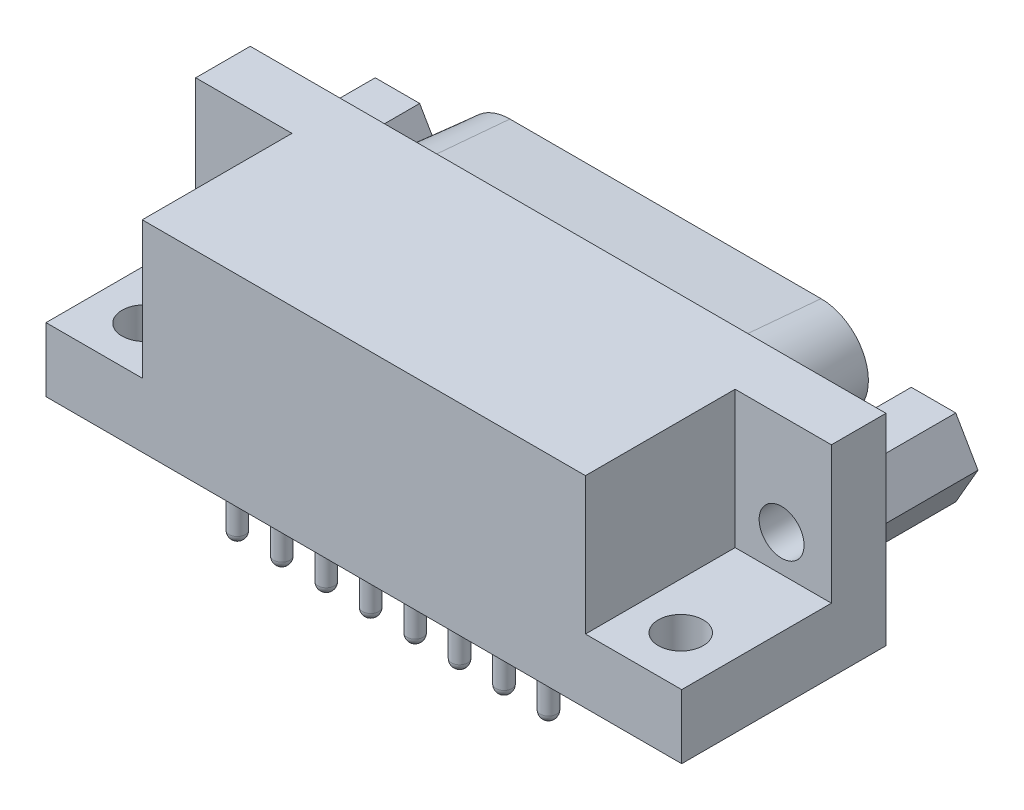
from build123d import *

# Parameters (mm, degrees)
SKETCH1_W                    = 39.62
SKETCH1_H                    = 12.55
BASE_EXTRUDE_DEPTH           = 1.77
BASE_EXTRUDE_DEPTH_BACK      = 10.96
SKETCH2_W                    = 7
SKETCH2_H                    = 10
CUT_EXTRUDE1_DEPTH           = 8.55
SKETCH4_R                    = 1.4
CUT_EXTRUDE3_DEPTH           = 33.652568291
SKETCH5_R                    = 1.4
CUT_EXTRUDE4_DEPTH           = 3
BOSS_EXTRUDE1_DEPTH          = 6.07
SKETCH7_R                    = 1.4
CUT_EXTRUDE5_DEPTH           = 6.07
BOSS_EXTRUDE3_DEPTH          = 6.07
BOSS_EXTRUDE3_TAPER          = 5
CUT_EXTRUDE7_DEPTH           = 6.07
CUT_EXTRUDE7_DRAFT           = 5
BOSS_EXTRUDE4_DEPTH          = 0.6
CUT_EXTRUDE8_START           = -0.6
SKETCH14_R                   = 0.75
CUT_EXTRUDE8_DEPTH           = 0.6
LPATTERN1_COUNT              = 7
LPATTERN1_PITCH              = 2.77
CUT_EXTRUDE9_START           = -0.6
SKETCH15_R                   = 0.75
CUT_EXTRUDE9_DEPTH           = 0.6
LPATTERN2_COUNT              = 8
LPATTERN2_PITCH              = 2.77
SKETCH16_R                   = 0.5
BOSS_EXTRUDE5_DEPTH          = 4.6
DOME1_FACE_RADIUS            = 0.5
DOME1_HEIGHT                 = 0.5
LPATTERN3_COUNT              = 7
LPATTERN3_PITCH              = 2.77
LPATTERN3_COPY_1_FACE_RADIUS = 0.5
LPATTERN3_COPY_1_HEIGHT      = 0.5
LPATTERN3_COPY_2_FACE_RADIUS = 0.5
LPATTERN3_COPY_2_HEIGHT      = 0.5
LPATTERN3_COPY_3_FACE_RADIUS = 0.5
LPATTERN3_COPY_3_HEIGHT      = 0.5
LPATTERN3_COPY_4_FACE_RADIUS = 0.5
LPATTERN3_COPY_4_HEIGHT      = 0.5
LPATTERN3_COPY_5_FACE_RADIUS = 0.5
LPATTERN3_COPY_5_HEIGHT      = 0.5
LPATTERN3_COPY_6_FACE_RADIUS = 0.5
LPATTERN3_COPY_6_HEIGHT      = 0.5
SKETCH17_R                   = 0.5
BOSS_EXTRUDE6_DEPTH          = 4.6
DOME2_FACE_RADIUS            = 0.5
DOME2_HEIGHT                 = 0.5
LPATTERN5_COUNT              = 8
LPATTERN5_PITCH              = 2.77
LPATTERN5_COPY_1_FACE_RADIUS = 0.5
LPATTERN5_COPY_1_HEIGHT      = 0.5
LPATTERN5_COPY_2_FACE_RADIUS = 0.5
LPATTERN5_COPY_2_HEIGHT      = 0.5
LPATTERN5_COPY_3_FACE_RADIUS = 0.5
LPATTERN5_COPY_3_HEIGHT      = 0.5
LPATTERN5_COPY_4_FACE_RADIUS = 0.5
LPATTERN5_COPY_4_HEIGHT      = 0.5
LPATTERN5_COPY_5_FACE_RADIUS = 0.5
LPATTERN5_COPY_5_HEIGHT      = 0.5
LPATTERN5_COPY_6_FACE_RADIUS = 0.5
LPATTERN5_COPY_6_HEIGHT      = 0.5
LPATTERN5_COPY_7_FACE_RADIUS = 0.5
LPATTERN5_COPY_7_HEIGHT      = 0.5
SKETCH18_R                   = 0.5
BOSS_EXTRUDE7_DEPTH          = 3
DOME3_FACE_RADIUS            = 0.5
DOME3_HEIGHT                 = 0.5
LPATTERN7_COUNT              = 8
LPATTERN7_PITCH              = 2.77
LPATTERN7_COPY_1_FACE_RADIUS = 0.5
LPATTERN7_COPY_1_HEIGHT      = 0.5
LPATTERN7_COPY_2_FACE_RADIUS = 0.5
LPATTERN7_COPY_2_HEIGHT      = 0.5
LPATTERN7_COPY_3_FACE_RADIUS = 0.5
LPATTERN7_COPY_3_HEIGHT      = 0.5
LPATTERN7_COPY_4_FACE_RADIUS = 0.5
LPATTERN7_COPY_4_HEIGHT      = 0.5
LPATTERN7_COPY_5_FACE_RADIUS = 0.5
LPATTERN7_COPY_5_HEIGHT      = 0.5
LPATTERN7_COPY_6_FACE_RADIUS = 0.5
LPATTERN7_COPY_6_HEIGHT      = 0.5
LPATTERN7_COPY_7_FACE_RADIUS = 0.5
LPATTERN7_COPY_7_HEIGHT      = 0.5
SKETCH19_R                   = 0.5
BOSS_EXTRUDE8_DEPTH          = 3
DOME4_FACE_RADIUS            = 0.5
DOME4_HEIGHT                 = 0.5
LPATTERN9_COUNT              = 7
LPATTERN9_PITCH              = 2.77
LPATTERN9_COPY_1_FACE_RADIUS = 0.5
LPATTERN9_COPY_1_HEIGHT      = 0.5
LPATTERN9_COPY_2_FACE_RADIUS = 0.5
LPATTERN9_COPY_2_HEIGHT      = 0.5
LPATTERN9_COPY_3_FACE_RADIUS = 0.5
LPATTERN9_COPY_3_HEIGHT      = 0.5
LPATTERN9_COPY_4_FACE_RADIUS = 0.5
LPATTERN9_COPY_4_HEIGHT      = 0.5
LPATTERN9_COPY_5_FACE_RADIUS = 0.5
LPATTERN9_COPY_5_HEIGHT      = 0.5
LPATTERN9_COPY_6_FACE_RADIUS = 0.5
LPATTERN9_COPY_6_HEIGHT      = 0.5


with BuildPart() as part:
    # Sketch1 → Base-Extrude (new, two sides)
    with BuildSketch(Plane.XY) as base_extrude_sk:
        with Locations((-9.736, 6.275)):
            Rectangle(SKETCH1_W, SKETCH1_H)
    extrude(amount=BASE_EXTRUDE_DEPTH)
    extrude(base_extrude_sk.sketch, amount=-BASE_EXTRUDE_DEPTH_BACK)

    # Sketch2 → Cut-Extrude1 (cut)
    with BuildSketch(Plane(origin=(0, 12.55, 0), x_dir=(-1, 0, 0), z_dir=(0, 1, 0))):
        with Locations((-7.574, -2.56)):
            Rectangle(SKETCH2_W, SKETCH2_H)
    cut_extrude1 = extrude(amount=-CUT_EXTRUDE1_DEPTH, mode=Mode.SUBTRACT)

    # Sketch4 → Cut-Extrude3 (cut, through all)
    with BuildSketch(Plane(origin=(0, 4, 0), x_dir=(-1, 0, 0), z_dir=(0, 1, 0))):
        with Locations(Location((-6.975, -1.27, 0), (0, 0, 90))):
            Circle(SKETCH4_R)
    cut_extrude3 = extrude(amount=-CUT_EXTRUDE3_DEPTH, mode=Mode.SUBTRACT)

    # Sketch5 → Cut-Extrude4 (cut)
    with BuildSketch(Plane.XY.offset(-7.56)):
        with Locations((6.97, 6.275)):
            Circle(SKETCH5_R)
    cut_extrude4 = extrude(amount=-CUT_EXTRUDE4_DEPTH, mode=Mode.SUBTRACT)

    # Sketch6 → Boss-Extrude1 (add)
    with BuildSketch(Plane(origin=(0, 0, -10.96), x_dir=(-1, 0, 0), z_dir=(0, 0, -1))):
        Polygon((-5.584359354, 8.675), (-8.355640646, 8.675), (-9.741281292, 6.275), (-8.355640646, 3.875), (-5.584359354, 3.875), (-4.198718708, 6.275), align=None)
    boss_extrude1 = extrude(amount=BOSS_EXTRUDE1_DEPTH)

    # Sketch7 → Cut-Extrude5 (cut)
    with BuildSketch(Plane(origin=(0, 0, -17.03), x_dir=(-1, 0, 0), z_dir=(0, 0, -1))):
        with Locations(Location((-6.97, 6.275, 0), (0, 0, 180))):
            Circle(SKETCH7_R)
    cut_extrude5 = extrude(amount=-CUT_EXTRUDE5_DEPTH, mode=Mode.SUBTRACT)

    # Mirror1: Cut-Extrude1, Cut-Extrude3, Cut-Extrude4, Boss-Extrude1, Cut-Extrude5 across plane
    add(cut_extrude1.mirror(Plane(origin=(-9.736, 0, 0), x_dir=(0, 0, 1), z_dir=(1, 0, 0))), mode=Mode.SUBTRACT)
    add(cut_extrude3.mirror(Plane(origin=(-9.736, 0, 0), x_dir=(0, 0, 1), z_dir=(1, 0, 0))), mode=Mode.SUBTRACT)
    add(cut_extrude4.mirror(Plane(origin=(-9.736, 0, 0), x_dir=(0, 0, 1), z_dir=(1, 0, 0))), mode=Mode.SUBTRACT)
    add(boss_extrude1.mirror(Plane(origin=(-9.736, 0, 0), x_dir=(0, 0, 1), z_dir=(1, 0, 0))))
    add(cut_extrude5.mirror(Plane(origin=(-9.736, 0, 0), x_dir=(0, 0, 1), z_dir=(1, 0, 0))), mode=Mode.SUBTRACT)

    # Sketch8 → Boss-Extrude3 (add)
    with BuildSketch(Plane(origin=(0, 0, -10.96), x_dir=(-1, 0, 0), z_dir=(0, 0, -1))):
        with BuildLine():
            ThreePointArc((18.046, 1.3739), (19.890769362, 1.902901897), (21.174861644, 3.329129093))
            Line((21.174861644, 3.329129093), (22.559861644, 6.169129093))
            ThreePointArc((22.559861644, 6.169129093), (22.383098103, 9.539769362), (19.431, 11.1761))
            Line((19.431, 11.1761), (0.041, 11.1761))
            ThreePointArc((0.041, 11.1761), (-2.911098103, 9.539769362), (-3.087861644, 6.169129093))
            Line((-3.087861644, 6.169129093), (-1.702861644, 3.329129093))
            ThreePointArc((-1.702861644, 3.329129093), (-0.418769362, 1.902901897), (1.426, 1.3739))
            Line((1.426, 1.3739), (18.046, 1.3739))
        make_face()
    extrude(amount=BOSS_EXTRUDE3_DEPTH, taper=BOSS_EXTRUDE3_TAPER)


with BuildPart() as cut_extrude7_tool:
    # Sketch12 → Cut-Extrude7 (with draft: the straight prism first)
    with BuildSketch(Plane(origin=(0, 0, -17.03), x_dir=(-1, 0, 0), z_dir=(0, 0, -1))):
        with BuildLine():
            Line((-2.251015246, 6.577239044), (-0.866015246, 3.737239044))
            ThreePointArc((-0.866015246, 3.737239044), (0.074633278, 2.692471057), (1.426, 2.304956188))
            Line((1.426, 2.304956188), (18.046, 2.304956188))
            ThreePointArc((18.046, 2.304956188), (19.397366722, 2.692471057), (20.338015246, 3.737239044))
            Line((20.338015246, 3.737239044), (21.723015246, 6.577239044))
            ThreePointArc((21.723015246, 6.577239044), (21.593528943, 9.046366722), (19.431, 10.245043812))
            Line((19.431, 10.245043812), (0.041, 10.245043812))
            ThreePointArc((0.041, 10.245043812), (-2.121528943, 9.046366722), (-2.251015246, 6.577239044))
        make_face()
    extrude(amount=-CUT_EXTRUDE7_DEPTH)
    # Cut-Extrude7: the draft: its side faces are tilted about the plane it starts from
    cut_extrude7_sides = [cut_extrude7_tool.faces().sort_by_distance(p)[0] for p in [
        (1.558515246, 5.157239044, -13.995),
        (-0.074633278, 2.692471057, -13.995),
        (-9.736, 2.304956188, -13.995),
        (-19.397366722, 2.692471057, -13.995),
        (-21.030515246, 5.157239044, -13.995),
        (-21.593528943, 9.046366722, -13.995),
        (-9.736, 10.245043812, -13.995),
        (2.121528943, 9.046366722, -13.995),
    ]]
    draft(cut_extrude7_sides, Plane(origin=(0, 0, -17.03), x_dir=(-1, 0, 0), z_dir=(0, 0, -1)), CUT_EXTRUDE7_DRAFT)


with BuildPart() as part_1:
    add(part.part)

    # Cut-Extrude7: cut by cut_extrude7_tool
    add(cut_extrude7_tool.part, mode=Mode.SUBTRACT)

    # Sketch13 → Boss-Extrude4 (add)
    with BuildSketch(Plane(origin=(0, 0, -10.96), x_dir=(-1, 0, 0), z_dir=(0, 0, -1))):
        with BuildLine():
            Line((-2.241987726, 6.581641549), (-0.856987726, 3.741641549))
            ThreePointArc((-0.856987726, 3.741641549), (0.079955882, 2.700988572), (1.426, 2.315))
            Line((1.426, 2.315), (18.046, 2.315))
            ThreePointArc((18.046, 2.315), (19.392044118, 2.700988572), (20.328987726, 3.741641549))
            Line((20.328987726, 3.741641549), (21.713987726, 6.581641549))
            ThreePointArc((21.713987726, 6.581641549), (21.585011428, 9.041044118), (19.431, 10.235))
            Line((19.431, 10.235), (0.041, 10.235))
            ThreePointArc((0.041, 10.235), (-2.113011428, 9.041044118), (-2.241987726, 6.581641549))
        make_face()
    extrude(amount=BOSS_EXTRUDE4_DEPTH)

    # Sketch14 → Cut-Extrude8 (cut)
    with BuildSketch(Plane(origin=(0, 0, -11.56), x_dir=(-1, 0, 0), z_dir=(0, 0, -1)).offset(CUT_EXTRUDE8_START)):
        with Locations((1.426, 4.855)):
            Circle(SKETCH14_R)
    cut_extrude8 = extrude(amount=CUT_EXTRUDE8_DEPTH, mode=Mode.SUBTRACT)

    # LPattern1: Cut-Extrude8 ×7
    with Locations(*[(-i * LPATTERN1_PITCH, 0, 0) for i in range(1, LPATTERN1_COUNT)]):
        add(cut_extrude8, mode=Mode.SUBTRACT)

    # Sketch15 → Cut-Extrude9 (cut)
    with BuildSketch(Plane(origin=(0, 0, -11.56), x_dir=(-1, 0, 0), z_dir=(0, 0, -1)).offset(CUT_EXTRUDE9_START)):
        with Locations((0.041, 7.695)):
            Circle(SKETCH15_R)
    cut_extrude9 = extrude(amount=CUT_EXTRUDE9_DEPTH, mode=Mode.SUBTRACT)

    # LPattern2: Cut-Extrude9 ×8
    with Locations(*[(-i * LPATTERN2_PITCH, 0, 0) for i in range(1, LPATTERN2_COUNT)]):
        add(cut_extrude9, mode=Mode.SUBTRACT)

    # Sketch16 → Boss-Extrude5 (add)
    with BuildSketch(Plane(origin=(0, 0, -10.96), x_dir=(-1, 0, 0), z_dir=(0, 0, -1))):
        with Locations(Location((1.426, 4.855, 0), (0, 0, 180))):
            Circle(SKETCH16_R)
    boss_extrude5 = extrude(amount=BOSS_EXTRUDE5_DEPTH)

    # Dome1: a dome of height H over a round flat face of radius A is a cap of a sphere of radius (A * A + H * H) / (2 * H)
    dome1_r = (DOME1_FACE_RADIUS * DOME1_FACE_RADIUS + DOME1_HEIGHT * DOME1_HEIGHT) / (2 * DOME1_HEIGHT)
    dome1_base = Plane((-1.426, 4.855, -15.56), z_dir=(0, 0, -1))
    with Locations(dome1_base.offset(DOME1_HEIGHT - dome1_r)):
        dome1_ball = Sphere(dome1_r, mode=Mode.PRIVATE)
    add(split(dome1_ball, bisect_by=dome1_base, keep=Keep.TOP, mode=Mode.PRIVATE))

    # LPattern3: Boss-Extrude5 ×7
    with Locations(*[(-i * LPATTERN3_PITCH, 0, 0) for i in range(1, LPATTERN3_COUNT)]):
        add(boss_extrude5)

    # LPattern3 copy 1: a dome of height H over a round flat face of radius A is a cap of a sphere of radius (A * A + H * H) / (2 * H)
    lpattern3_copy_1_r = (LPATTERN3_COPY_1_FACE_RADIUS * LPATTERN3_COPY_1_FACE_RADIUS + LPATTERN3_COPY_1_HEIGHT * LPATTERN3_COPY_1_HEIGHT) / (2 * LPATTERN3_COPY_1_HEIGHT)
    lpattern3_copy_1_base = Plane((-4.196, 4.855, -15.56), z_dir=(0, 0, -1))
    with Locations(lpattern3_copy_1_base.offset(LPATTERN3_COPY_1_HEIGHT - lpattern3_copy_1_r)):
        lpattern3_copy_1_ball = Sphere(lpattern3_copy_1_r, mode=Mode.PRIVATE)
    add(split(lpattern3_copy_1_ball, bisect_by=lpattern3_copy_1_base, keep=Keep.TOP, mode=Mode.PRIVATE))

    # LPattern3 copy 2: a dome of height H over a round flat face of radius A is a cap of a sphere of radius (A * A + H * H) / (2 * H)
    lpattern3_copy_2_r = (LPATTERN3_COPY_2_FACE_RADIUS * LPATTERN3_COPY_2_FACE_RADIUS + LPATTERN3_COPY_2_HEIGHT * LPATTERN3_COPY_2_HEIGHT) / (2 * LPATTERN3_COPY_2_HEIGHT)
    lpattern3_copy_2_base = Plane((-6.966, 4.855, -15.56), z_dir=(0, 0, -1))
    with Locations(lpattern3_copy_2_base.offset(LPATTERN3_COPY_2_HEIGHT - lpattern3_copy_2_r)):
        lpattern3_copy_2_ball = Sphere(lpattern3_copy_2_r, mode=Mode.PRIVATE)
    add(split(lpattern3_copy_2_ball, bisect_by=lpattern3_copy_2_base, keep=Keep.TOP, mode=Mode.PRIVATE))

    # LPattern3 copy 3: a dome of height H over a round flat face of radius A is a cap of a sphere of radius (A * A + H * H) / (2 * H)
    lpattern3_copy_3_r = (LPATTERN3_COPY_3_FACE_RADIUS * LPATTERN3_COPY_3_FACE_RADIUS + LPATTERN3_COPY_3_HEIGHT * LPATTERN3_COPY_3_HEIGHT) / (2 * LPATTERN3_COPY_3_HEIGHT)
    lpattern3_copy_3_base = Plane((-9.736, 4.855, -15.56), z_dir=(0, 0, -1))
    with Locations(lpattern3_copy_3_base.offset(LPATTERN3_COPY_3_HEIGHT - lpattern3_copy_3_r)):
        lpattern3_copy_3_ball = Sphere(lpattern3_copy_3_r, mode=Mode.PRIVATE)
    add(split(lpattern3_copy_3_ball, bisect_by=lpattern3_copy_3_base, keep=Keep.TOP, mode=Mode.PRIVATE))

    # LPattern3 copy 4: a dome of height H over a round flat face of radius A is a cap of a sphere of radius (A * A + H * H) / (2 * H)
    lpattern3_copy_4_r = (LPATTERN3_COPY_4_FACE_RADIUS * LPATTERN3_COPY_4_FACE_RADIUS + LPATTERN3_COPY_4_HEIGHT * LPATTERN3_COPY_4_HEIGHT) / (2 * LPATTERN3_COPY_4_HEIGHT)
    lpattern3_copy_4_base = Plane((-12.506, 4.855, -15.56), z_dir=(0, 0, -1))
    with Locations(lpattern3_copy_4_base.offset(LPATTERN3_COPY_4_HEIGHT - lpattern3_copy_4_r)):
        lpattern3_copy_4_ball = Sphere(lpattern3_copy_4_r, mode=Mode.PRIVATE)
    add(split(lpattern3_copy_4_ball, bisect_by=lpattern3_copy_4_base, keep=Keep.TOP, mode=Mode.PRIVATE))

    # LPattern3 copy 5: a dome of height H over a round flat face of radius A is a cap of a sphere of radius (A * A + H * H) / (2 * H)
    lpattern3_copy_5_r = (LPATTERN3_COPY_5_FACE_RADIUS * LPATTERN3_COPY_5_FACE_RADIUS + LPATTERN3_COPY_5_HEIGHT * LPATTERN3_COPY_5_HEIGHT) / (2 * LPATTERN3_COPY_5_HEIGHT)
    lpattern3_copy_5_base = Plane((-15.276, 4.855, -15.56), z_dir=(0, 0, -1))
    with Locations(lpattern3_copy_5_base.offset(LPATTERN3_COPY_5_HEIGHT - lpattern3_copy_5_r)):
        lpattern3_copy_5_ball = Sphere(lpattern3_copy_5_r, mode=Mode.PRIVATE)
    add(split(lpattern3_copy_5_ball, bisect_by=lpattern3_copy_5_base, keep=Keep.TOP, mode=Mode.PRIVATE))

    # LPattern3 copy 6: a dome of height H over a round flat face of radius A is a cap of a sphere of radius (A * A + H * H) / (2 * H)
    lpattern3_copy_6_r = (LPATTERN3_COPY_6_FACE_RADIUS * LPATTERN3_COPY_6_FACE_RADIUS + LPATTERN3_COPY_6_HEIGHT * LPATTERN3_COPY_6_HEIGHT) / (2 * LPATTERN3_COPY_6_HEIGHT)
    lpattern3_copy_6_base = Plane((-18.046, 4.855, -15.56), z_dir=(0, 0, -1))
    with Locations(lpattern3_copy_6_base.offset(LPATTERN3_COPY_6_HEIGHT - lpattern3_copy_6_r)):
        lpattern3_copy_6_ball = Sphere(lpattern3_copy_6_r, mode=Mode.PRIVATE)
    add(split(lpattern3_copy_6_ball, bisect_by=lpattern3_copy_6_base, keep=Keep.TOP, mode=Mode.PRIVATE))

    # Sketch17 → Boss-Extrude6 (add)
    with BuildSketch(Plane(origin=(0, 0, -10.96), x_dir=(-1, 0, 0), z_dir=(0, 0, -1))):
        with Locations(Location((0.041, 7.695, 0), (0, 0, 180))):
            Circle(SKETCH17_R)
    boss_extrude6 = extrude(amount=BOSS_EXTRUDE6_DEPTH)

    # Dome2: a dome of height H over a round flat face of radius A is a cap of a sphere of radius (A * A + H * H) / (2 * H)
    dome2_r = (DOME2_FACE_RADIUS * DOME2_FACE_RADIUS + DOME2_HEIGHT * DOME2_HEIGHT) / (2 * DOME2_HEIGHT)
    dome2_base = Plane((-0.041, 7.695, -15.56), z_dir=(0, 0, -1))
    with Locations(dome2_base.offset(DOME2_HEIGHT - dome2_r)):
        dome2_ball = Sphere(dome2_r, mode=Mode.PRIVATE)
    add(split(dome2_ball, bisect_by=dome2_base, keep=Keep.TOP, mode=Mode.PRIVATE))

    # LPattern5: Boss-Extrude6 ×8
    with Locations(*[(-i * LPATTERN5_PITCH, 0, 0) for i in range(1, LPATTERN5_COUNT)]):
        add(boss_extrude6)

    # LPattern5 copy 1: a dome of height H over a round flat face of radius A is a cap of a sphere of radius (A * A + H * H) / (2 * H)
    lpattern5_copy_1_r = (LPATTERN5_COPY_1_FACE_RADIUS * LPATTERN5_COPY_1_FACE_RADIUS + LPATTERN5_COPY_1_HEIGHT * LPATTERN5_COPY_1_HEIGHT) / (2 * LPATTERN5_COPY_1_HEIGHT)
    lpattern5_copy_1_base = Plane((-2.811, 7.695, -15.56), z_dir=(0, 0, -1))
    with Locations(lpattern5_copy_1_base.offset(LPATTERN5_COPY_1_HEIGHT - lpattern5_copy_1_r)):
        lpattern5_copy_1_ball = Sphere(lpattern5_copy_1_r, mode=Mode.PRIVATE)
    add(split(lpattern5_copy_1_ball, bisect_by=lpattern5_copy_1_base, keep=Keep.TOP, mode=Mode.PRIVATE))

    # LPattern5 copy 2: a dome of height H over a round flat face of radius A is a cap of a sphere of radius (A * A + H * H) / (2 * H)
    lpattern5_copy_2_r = (LPATTERN5_COPY_2_FACE_RADIUS * LPATTERN5_COPY_2_FACE_RADIUS + LPATTERN5_COPY_2_HEIGHT * LPATTERN5_COPY_2_HEIGHT) / (2 * LPATTERN5_COPY_2_HEIGHT)
    lpattern5_copy_2_base = Plane((-5.581, 7.695, -15.56), z_dir=(0, 0, -1))
    with Locations(lpattern5_copy_2_base.offset(LPATTERN5_COPY_2_HEIGHT - lpattern5_copy_2_r)):
        lpattern5_copy_2_ball = Sphere(lpattern5_copy_2_r, mode=Mode.PRIVATE)
    add(split(lpattern5_copy_2_ball, bisect_by=lpattern5_copy_2_base, keep=Keep.TOP, mode=Mode.PRIVATE))

    # LPattern5 copy 3: a dome of height H over a round flat face of radius A is a cap of a sphere of radius (A * A + H * H) / (2 * H)
    lpattern5_copy_3_r = (LPATTERN5_COPY_3_FACE_RADIUS * LPATTERN5_COPY_3_FACE_RADIUS + LPATTERN5_COPY_3_HEIGHT * LPATTERN5_COPY_3_HEIGHT) / (2 * LPATTERN5_COPY_3_HEIGHT)
    lpattern5_copy_3_base = Plane((-8.351, 7.695, -15.56), z_dir=(0, 0, -1))
    with Locations(lpattern5_copy_3_base.offset(LPATTERN5_COPY_3_HEIGHT - lpattern5_copy_3_r)):
        lpattern5_copy_3_ball = Sphere(lpattern5_copy_3_r, mode=Mode.PRIVATE)
    add(split(lpattern5_copy_3_ball, bisect_by=lpattern5_copy_3_base, keep=Keep.TOP, mode=Mode.PRIVATE))

    # LPattern5 copy 4: a dome of height H over a round flat face of radius A is a cap of a sphere of radius (A * A + H * H) / (2 * H)
    lpattern5_copy_4_r = (LPATTERN5_COPY_4_FACE_RADIUS * LPATTERN5_COPY_4_FACE_RADIUS + LPATTERN5_COPY_4_HEIGHT * LPATTERN5_COPY_4_HEIGHT) / (2 * LPATTERN5_COPY_4_HEIGHT)
    lpattern5_copy_4_base = Plane((-11.121, 7.695, -15.56), z_dir=(0, 0, -1))
    with Locations(lpattern5_copy_4_base.offset(LPATTERN5_COPY_4_HEIGHT - lpattern5_copy_4_r)):
        lpattern5_copy_4_ball = Sphere(lpattern5_copy_4_r, mode=Mode.PRIVATE)
    add(split(lpattern5_copy_4_ball, bisect_by=lpattern5_copy_4_base, keep=Keep.TOP, mode=Mode.PRIVATE))

    # LPattern5 copy 5: a dome of height H over a round flat face of radius A is a cap of a sphere of radius (A * A + H * H) / (2 * H)
    lpattern5_copy_5_r = (LPATTERN5_COPY_5_FACE_RADIUS * LPATTERN5_COPY_5_FACE_RADIUS + LPATTERN5_COPY_5_HEIGHT * LPATTERN5_COPY_5_HEIGHT) / (2 * LPATTERN5_COPY_5_HEIGHT)
    lpattern5_copy_5_base = Plane((-13.891, 7.695, -15.56), z_dir=(0, 0, -1))
    with Locations(lpattern5_copy_5_base.offset(LPATTERN5_COPY_5_HEIGHT - lpattern5_copy_5_r)):
        lpattern5_copy_5_ball = Sphere(lpattern5_copy_5_r, mode=Mode.PRIVATE)
    add(split(lpattern5_copy_5_ball, bisect_by=lpattern5_copy_5_base, keep=Keep.TOP, mode=Mode.PRIVATE))

    # LPattern5 copy 6: a dome of height H over a round flat face of radius A is a cap of a sphere of radius (A * A + H * H) / (2 * H)
    lpattern5_copy_6_r = (LPATTERN5_COPY_6_FACE_RADIUS * LPATTERN5_COPY_6_FACE_RADIUS + LPATTERN5_COPY_6_HEIGHT * LPATTERN5_COPY_6_HEIGHT) / (2 * LPATTERN5_COPY_6_HEIGHT)
    lpattern5_copy_6_base = Plane((-16.661, 7.695, -15.56), z_dir=(0, 0, -1))
    with Locations(lpattern5_copy_6_base.offset(LPATTERN5_COPY_6_HEIGHT - lpattern5_copy_6_r)):
        lpattern5_copy_6_ball = Sphere(lpattern5_copy_6_r, mode=Mode.PRIVATE)
    add(split(lpattern5_copy_6_ball, bisect_by=lpattern5_copy_6_base, keep=Keep.TOP, mode=Mode.PRIVATE))

    # LPattern5 copy 7: a dome of height H over a round flat face of radius A is a cap of a sphere of radius (A * A + H * H) / (2 * H)
    lpattern5_copy_7_r = (LPATTERN5_COPY_7_FACE_RADIUS * LPATTERN5_COPY_7_FACE_RADIUS + LPATTERN5_COPY_7_HEIGHT * LPATTERN5_COPY_7_HEIGHT) / (2 * LPATTERN5_COPY_7_HEIGHT)
    lpattern5_copy_7_base = Plane((-19.431, 7.695, -15.56), z_dir=(0, 0, -1))
    with Locations(lpattern5_copy_7_base.offset(LPATTERN5_COPY_7_HEIGHT - lpattern5_copy_7_r)):
        lpattern5_copy_7_ball = Sphere(lpattern5_copy_7_r, mode=Mode.PRIVATE)
    add(split(lpattern5_copy_7_ball, bisect_by=lpattern5_copy_7_base, keep=Keep.TOP, mode=Mode.PRIVATE))

    # Sketch18 → Boss-Extrude7 (add)
    with BuildSketch(Plane.XZ):
        with Locations(Location((0, 0, 0), (0, 0, 90))):
            Circle(SKETCH18_R)
    boss_extrude7 = extrude(amount=BOSS_EXTRUDE7_DEPTH)

    # Dome3: a dome of height H over a round flat face of radius A is a cap of a sphere of radius (A * A + H * H) / (2 * H)
    dome3_r = (DOME3_FACE_RADIUS * DOME3_FACE_RADIUS + DOME3_HEIGHT * DOME3_HEIGHT) / (2 * DOME3_HEIGHT)
    dome3_base = Plane((0, -3, 0), z_dir=(0, -1, 0))
    with Locations(dome3_base.offset(DOME3_HEIGHT - dome3_r)):
        dome3_ball = Sphere(dome3_r, mode=Mode.PRIVATE)
    add(split(dome3_ball, bisect_by=dome3_base, keep=Keep.TOP, mode=Mode.PRIVATE))

    # LPattern7: Boss-Extrude7 ×8
    with Locations(*[(-i * LPATTERN7_PITCH, 0, 0) for i in range(1, LPATTERN7_COUNT)]):
        add(boss_extrude7)

    # LPattern7 copy 1: a dome of height H over a round flat face of radius A is a cap of a sphere of radius (A * A + H * H) / (2 * H)
    lpattern7_copy_1_r = (LPATTERN7_COPY_1_FACE_RADIUS * LPATTERN7_COPY_1_FACE_RADIUS + LPATTERN7_COPY_1_HEIGHT * LPATTERN7_COPY_1_HEIGHT) / (2 * LPATTERN7_COPY_1_HEIGHT)
    lpattern7_copy_1_base = Plane((-2.77, -3, 0), z_dir=(0, -1, 0))
    with Locations(lpattern7_copy_1_base.offset(LPATTERN7_COPY_1_HEIGHT - lpattern7_copy_1_r)):
        lpattern7_copy_1_ball = Sphere(lpattern7_copy_1_r, mode=Mode.PRIVATE)
    add(split(lpattern7_copy_1_ball, bisect_by=lpattern7_copy_1_base, keep=Keep.TOP, mode=Mode.PRIVATE))

    # LPattern7 copy 2: a dome of height H over a round flat face of radius A is a cap of a sphere of radius (A * A + H * H) / (2 * H)
    lpattern7_copy_2_r = (LPATTERN7_COPY_2_FACE_RADIUS * LPATTERN7_COPY_2_FACE_RADIUS + LPATTERN7_COPY_2_HEIGHT * LPATTERN7_COPY_2_HEIGHT) / (2 * LPATTERN7_COPY_2_HEIGHT)
    lpattern7_copy_2_base = Plane((-5.54, -3, 0), z_dir=(0, -1, 0))
    with Locations(lpattern7_copy_2_base.offset(LPATTERN7_COPY_2_HEIGHT - lpattern7_copy_2_r)):
        lpattern7_copy_2_ball = Sphere(lpattern7_copy_2_r, mode=Mode.PRIVATE)
    add(split(lpattern7_copy_2_ball, bisect_by=lpattern7_copy_2_base, keep=Keep.TOP, mode=Mode.PRIVATE))

    # LPattern7 copy 3: a dome of height H over a round flat face of radius A is a cap of a sphere of radius (A * A + H * H) / (2 * H)
    lpattern7_copy_3_r = (LPATTERN7_COPY_3_FACE_RADIUS * LPATTERN7_COPY_3_FACE_RADIUS + LPATTERN7_COPY_3_HEIGHT * LPATTERN7_COPY_3_HEIGHT) / (2 * LPATTERN7_COPY_3_HEIGHT)
    lpattern7_copy_3_base = Plane((-8.31, -3, 0), z_dir=(0, -1, 0))
    with Locations(lpattern7_copy_3_base.offset(LPATTERN7_COPY_3_HEIGHT - lpattern7_copy_3_r)):
        lpattern7_copy_3_ball = Sphere(lpattern7_copy_3_r, mode=Mode.PRIVATE)
    add(split(lpattern7_copy_3_ball, bisect_by=lpattern7_copy_3_base, keep=Keep.TOP, mode=Mode.PRIVATE))

    # LPattern7 copy 4: a dome of height H over a round flat face of radius A is a cap of a sphere of radius (A * A + H * H) / (2 * H)
    lpattern7_copy_4_r = (LPATTERN7_COPY_4_FACE_RADIUS * LPATTERN7_COPY_4_FACE_RADIUS + LPATTERN7_COPY_4_HEIGHT * LPATTERN7_COPY_4_HEIGHT) / (2 * LPATTERN7_COPY_4_HEIGHT)
    lpattern7_copy_4_base = Plane((-11.08, -3, 0), z_dir=(0, -1, 0))
    with Locations(lpattern7_copy_4_base.offset(LPATTERN7_COPY_4_HEIGHT - lpattern7_copy_4_r)):
        lpattern7_copy_4_ball = Sphere(lpattern7_copy_4_r, mode=Mode.PRIVATE)
    add(split(lpattern7_copy_4_ball, bisect_by=lpattern7_copy_4_base, keep=Keep.TOP, mode=Mode.PRIVATE))

    # LPattern7 copy 5: a dome of height H over a round flat face of radius A is a cap of a sphere of radius (A * A + H * H) / (2 * H)
    lpattern7_copy_5_r = (LPATTERN7_COPY_5_FACE_RADIUS * LPATTERN7_COPY_5_FACE_RADIUS + LPATTERN7_COPY_5_HEIGHT * LPATTERN7_COPY_5_HEIGHT) / (2 * LPATTERN7_COPY_5_HEIGHT)
    lpattern7_copy_5_base = Plane((-13.85, -3, 0), z_dir=(0, -1, 0))
    with Locations(lpattern7_copy_5_base.offset(LPATTERN7_COPY_5_HEIGHT - lpattern7_copy_5_r)):
        lpattern7_copy_5_ball = Sphere(lpattern7_copy_5_r, mode=Mode.PRIVATE)
    add(split(lpattern7_copy_5_ball, bisect_by=lpattern7_copy_5_base, keep=Keep.TOP, mode=Mode.PRIVATE))

    # LPattern7 copy 6: a dome of height H over a round flat face of radius A is a cap of a sphere of radius (A * A + H * H) / (2 * H)
    lpattern7_copy_6_r = (LPATTERN7_COPY_6_FACE_RADIUS * LPATTERN7_COPY_6_FACE_RADIUS + LPATTERN7_COPY_6_HEIGHT * LPATTERN7_COPY_6_HEIGHT) / (2 * LPATTERN7_COPY_6_HEIGHT)
    lpattern7_copy_6_base = Plane((-16.62, -3, 0), z_dir=(0, -1, 0))
    with Locations(lpattern7_copy_6_base.offset(LPATTERN7_COPY_6_HEIGHT - lpattern7_copy_6_r)):
        lpattern7_copy_6_ball = Sphere(lpattern7_copy_6_r, mode=Mode.PRIVATE)
    add(split(lpattern7_copy_6_ball, bisect_by=lpattern7_copy_6_base, keep=Keep.TOP, mode=Mode.PRIVATE))

    # LPattern7 copy 7: a dome of height H over a round flat face of radius A is a cap of a sphere of radius (A * A + H * H) / (2 * H)
    lpattern7_copy_7_r = (LPATTERN7_COPY_7_FACE_RADIUS * LPATTERN7_COPY_7_FACE_RADIUS + LPATTERN7_COPY_7_HEIGHT * LPATTERN7_COPY_7_HEIGHT) / (2 * LPATTERN7_COPY_7_HEIGHT)
    lpattern7_copy_7_base = Plane((-19.39, -3, 0), z_dir=(0, -1, 0))
    with Locations(lpattern7_copy_7_base.offset(LPATTERN7_COPY_7_HEIGHT - lpattern7_copy_7_r)):
        lpattern7_copy_7_ball = Sphere(lpattern7_copy_7_r, mode=Mode.PRIVATE)
    add(split(lpattern7_copy_7_ball, bisect_by=lpattern7_copy_7_base, keep=Keep.TOP, mode=Mode.PRIVATE))

    # Sketch19 → Boss-Extrude8 (add)
    with BuildSketch(Plane.XZ):
        with Locations(Location((-1.38, -2.84, 0), (0, 0, 90))):
            Circle(SKETCH19_R)
    boss_extrude8 = extrude(amount=BOSS_EXTRUDE8_DEPTH)

    # Dome4: a dome of height H over a round flat face of radius A is a cap of a sphere of radius (A * A + H * H) / (2 * H)
    dome4_r = (DOME4_FACE_RADIUS * DOME4_FACE_RADIUS + DOME4_HEIGHT * DOME4_HEIGHT) / (2 * DOME4_HEIGHT)
    dome4_base = Plane((-1.38, -3, -2.84), z_dir=(0, -1, 0))
    with Locations(dome4_base.offset(DOME4_HEIGHT - dome4_r)):
        dome4_ball = Sphere(dome4_r, mode=Mode.PRIVATE)
    add(split(dome4_ball, bisect_by=dome4_base, keep=Keep.TOP, mode=Mode.PRIVATE))

    # LPattern9: Boss-Extrude8 ×7
    with Locations(*[(-i * LPATTERN9_PITCH, 0, 0) for i in range(1, LPATTERN9_COUNT)]):
        add(boss_extrude8)

    # LPattern9 copy 1: a dome of height H over a round flat face of radius A is a cap of a sphere of radius (A * A + H * H) / (2 * H)
    lpattern9_copy_1_r = (LPATTERN9_COPY_1_FACE_RADIUS * LPATTERN9_COPY_1_FACE_RADIUS + LPATTERN9_COPY_1_HEIGHT * LPATTERN9_COPY_1_HEIGHT) / (2 * LPATTERN9_COPY_1_HEIGHT)
    lpattern9_copy_1_base = Plane((-4.15, -3, -2.84), z_dir=(0, -1, 0))
    with Locations(lpattern9_copy_1_base.offset(LPATTERN9_COPY_1_HEIGHT - lpattern9_copy_1_r)):
        lpattern9_copy_1_ball = Sphere(lpattern9_copy_1_r, mode=Mode.PRIVATE)
    add(split(lpattern9_copy_1_ball, bisect_by=lpattern9_copy_1_base, keep=Keep.TOP, mode=Mode.PRIVATE))

    # LPattern9 copy 2: a dome of height H over a round flat face of radius A is a cap of a sphere of radius (A * A + H * H) / (2 * H)
    lpattern9_copy_2_r = (LPATTERN9_COPY_2_FACE_RADIUS * LPATTERN9_COPY_2_FACE_RADIUS + LPATTERN9_COPY_2_HEIGHT * LPATTERN9_COPY_2_HEIGHT) / (2 * LPATTERN9_COPY_2_HEIGHT)
    lpattern9_copy_2_base = Plane((-6.92, -3, -2.84), z_dir=(0, -1, 0))
    with Locations(lpattern9_copy_2_base.offset(LPATTERN9_COPY_2_HEIGHT - lpattern9_copy_2_r)):
        lpattern9_copy_2_ball = Sphere(lpattern9_copy_2_r, mode=Mode.PRIVATE)
    add(split(lpattern9_copy_2_ball, bisect_by=lpattern9_copy_2_base, keep=Keep.TOP, mode=Mode.PRIVATE))

    # LPattern9 copy 3: a dome of height H over a round flat face of radius A is a cap of a sphere of radius (A * A + H * H) / (2 * H)
    lpattern9_copy_3_r = (LPATTERN9_COPY_3_FACE_RADIUS * LPATTERN9_COPY_3_FACE_RADIUS + LPATTERN9_COPY_3_HEIGHT * LPATTERN9_COPY_3_HEIGHT) / (2 * LPATTERN9_COPY_3_HEIGHT)
    lpattern9_copy_3_base = Plane((-9.69, -3, -2.84), z_dir=(0, -1, 0))
    with Locations(lpattern9_copy_3_base.offset(LPATTERN9_COPY_3_HEIGHT - lpattern9_copy_3_r)):
        lpattern9_copy_3_ball = Sphere(lpattern9_copy_3_r, mode=Mode.PRIVATE)
    add(split(lpattern9_copy_3_ball, bisect_by=lpattern9_copy_3_base, keep=Keep.TOP, mode=Mode.PRIVATE))

    # LPattern9 copy 4: a dome of height H over a round flat face of radius A is a cap of a sphere of radius (A * A + H * H) / (2 * H)
    lpattern9_copy_4_r = (LPATTERN9_COPY_4_FACE_RADIUS * LPATTERN9_COPY_4_FACE_RADIUS + LPATTERN9_COPY_4_HEIGHT * LPATTERN9_COPY_4_HEIGHT) / (2 * LPATTERN9_COPY_4_HEIGHT)
    lpattern9_copy_4_base = Plane((-12.46, -3, -2.84), z_dir=(0, -1, 0))
    with Locations(lpattern9_copy_4_base.offset(LPATTERN9_COPY_4_HEIGHT - lpattern9_copy_4_r)):
        lpattern9_copy_4_ball = Sphere(lpattern9_copy_4_r, mode=Mode.PRIVATE)
    add(split(lpattern9_copy_4_ball, bisect_by=lpattern9_copy_4_base, keep=Keep.TOP, mode=Mode.PRIVATE))

    # LPattern9 copy 5: a dome of height H over a round flat face of radius A is a cap of a sphere of radius (A * A + H * H) / (2 * H)
    lpattern9_copy_5_r = (LPATTERN9_COPY_5_FACE_RADIUS * LPATTERN9_COPY_5_FACE_RADIUS + LPATTERN9_COPY_5_HEIGHT * LPATTERN9_COPY_5_HEIGHT) / (2 * LPATTERN9_COPY_5_HEIGHT)
    lpattern9_copy_5_base = Plane((-15.23, -3, -2.84), z_dir=(0, -1, 0))
    with Locations(lpattern9_copy_5_base.offset(LPATTERN9_COPY_5_HEIGHT - lpattern9_copy_5_r)):
        lpattern9_copy_5_ball = Sphere(lpattern9_copy_5_r, mode=Mode.PRIVATE)
    add(split(lpattern9_copy_5_ball, bisect_by=lpattern9_copy_5_base, keep=Keep.TOP, mode=Mode.PRIVATE))

    # LPattern9 copy 6: a dome of height H over a round flat face of radius A is a cap of a sphere of radius (A * A + H * H) / (2 * H)
    lpattern9_copy_6_r = (LPATTERN9_COPY_6_FACE_RADIUS * LPATTERN9_COPY_6_FACE_RADIUS + LPATTERN9_COPY_6_HEIGHT * LPATTERN9_COPY_6_HEIGHT) / (2 * LPATTERN9_COPY_6_HEIGHT)
    lpattern9_copy_6_base = Plane((-18, -3, -2.84), z_dir=(0, -1, 0))
    with Locations(lpattern9_copy_6_base.offset(LPATTERN9_COPY_6_HEIGHT - lpattern9_copy_6_r)):
        lpattern9_copy_6_ball = Sphere(lpattern9_copy_6_r, mode=Mode.PRIVATE)
    add(split(lpattern9_copy_6_ball, bisect_by=lpattern9_copy_6_base, keep=Keep.TOP, mode=Mode.PRIVATE))


solid = part_1.part
